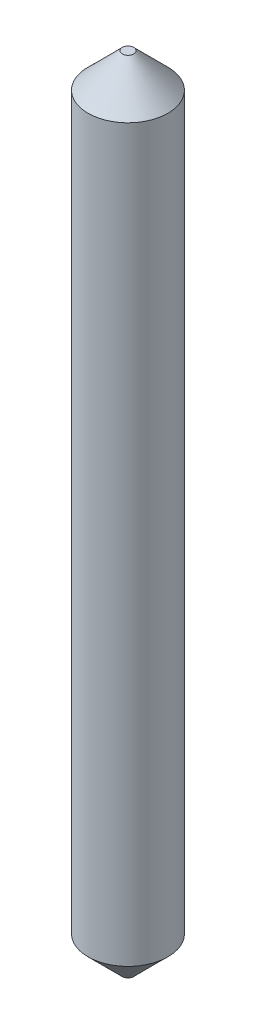
from build123d import *

# Parameters (mm, degrees)
SKETCH_1_R      = 0.35
EXTRUDE_1_DEPTH = 7
CHAMFER_1_SIZE  = 0.3


with BuildPart() as part:
    # Эскиз1 → Бобышка-Вытянуть1 (new body)
    with BuildSketch(Plane(origin=(0, 0, 0), x_dir=(1, 0, 0), z_dir=(0, 1, 0))):
        Circle(SKETCH_1_R)
    extrude(amount=EXTRUDE_1_DEPTH)

    # Фаска1
    chamfer_1_edges = [part.edges().sort_by_distance(p)[0] for p in [
        (-0.35, 0, 0),
        (-0.35, 7, 0),
    ]]
    chamfer(chamfer_1_edges, length=CHAMFER_1_SIZE)


solid = part.part
